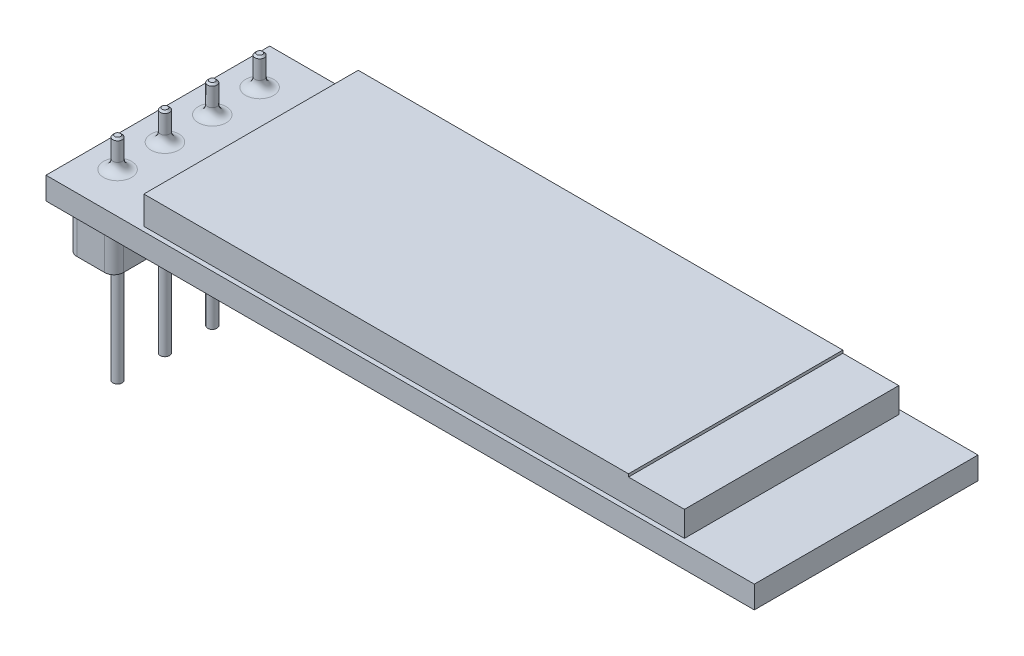
from build123d import *

# Parameters (mm, degrees)
SKETCH1_W                  = 38
SKETCH1_H                  = 12
BOSS_EXTRUDE1_DEPTH        = 1.2
SKETCH2_W                  = 29
SKETCH2_H                  = 11.5
BOSS_EXTRUDE2_DEPTH        = 1.5
BOSS_EXTRUDE3_START        = -9.8
SKETCH3_R                  = 0.25
BOSS_EXTRUDE3_DEPTH        = 11.4
CHAMFER1_SIZE              = 0.1
FILLET1_R                  = 0.5
LPATTERN1_COUNT            = 4
LPATTERN1_PITCH            = 2.54
CHAMFER1_OF_LPATTERN1_SIZE = 0.1
FILLET1_OF_LPATTERN1_R     = 0.5
SKETCH4_W                  = 2.5
SKETCH4_H                  = 10.5
BOSS_EXTRUDE4_DEPTH        = 2.5
FILLET2_R                  = 0.5
SKETCH5_W                  = 3
SKETCH5_H                  = 11.5
CUT_EXTRUDE1_DEPTH         = 0.15


with BuildPart() as part:
    # Sketch1 → Boss-Extrude1 (new body)
    with BuildSketch(Plane(origin=(0, 0, 0), x_dir=(1, 0, 0), z_dir=(0, 1, 0))):
        Rectangle(SKETCH1_W, SKETCH1_H)
    extrude(amount=BOSS_EXTRUDE1_DEPTH)

    # Sketch2 → Boss-Extrude2 (add)
    with BuildSketch(Plane(origin=(0, 1.2, 0), x_dir=(1, 0, 0), z_dir=(0, 1, 0))):
        with Locations((0.5, 0)):
            Rectangle(SKETCH2_W, SKETCH2_H)
    extrude(amount=BOSS_EXTRUDE2_DEPTH)

    # Sketch3 → Boss-Extrude3 (add)
    with BuildSketch(Plane(origin=(0, 1.2, 0), x_dir=(1, 0, 0), z_dir=(0, 1, 0)).offset(BOSS_EXTRUDE3_START)):
        with Locations((-17.35, -3.81)):
            Circle(SKETCH3_R)
    boss_extrude3 = extrude(amount=BOSS_EXTRUDE3_DEPTH)

    # Chamfer1
    chamfer1_edges = [part.edges().sort_by_distance(p)[0] for p in [
        (-17.6, 2.8, 3.81),
    ]]
    chamfer(chamfer1_edges, length=CHAMFER1_SIZE)

    # Fillet1
    fillet1_edges = [part.edges().sort_by_distance(p)[0] for p in [
        (-17.6, 1.2, 3.81),
    ]]
    fillet(fillet1_edges, radius=FILLET1_R)

    # LPattern1: Boss-Extrude3 ×4
    with Locations(*[(0, 0, -i * LPATTERN1_PITCH) for i in range(1, LPATTERN1_COUNT)]):
        add(boss_extrude3)

    # Chamfer1 of LPattern1
    chamfer1_of_lpattern1_edges = [part.edges().sort_by_distance(p)[0] for p in [
        (-17.6, 2.8, 1.27),
        (-17.6, 2.8, -1.27),
        (-17.6, 2.8, -3.81),
    ]]
    chamfer(chamfer1_of_lpattern1_edges, length=CHAMFER1_OF_LPATTERN1_SIZE)

    # Fillet1 of LPattern1
    fillet1_of_lpattern1_edges = [part.edges().sort_by_distance(p)[0] for p in [
        (-17.6, 1.2, 1.27),
        (-17.6, 1.2, -1.27),
        (-17.6, 1.2, -3.81),
    ]]
    fillet(fillet1_of_lpattern1_edges, radius=FILLET1_OF_LPATTERN1_R)

    # Sketch4 → Boss-Extrude4 (add)
    with BuildSketch(Plane.XZ):
        with Locations((-17.35, 0)):
            Rectangle(SKETCH4_W, SKETCH4_H)
    extrude(amount=BOSS_EXTRUDE4_DEPTH)

    # Fillet2
    fillet2_edges = [part.edges().sort_by_distance(p)[0] for p in [
        (-16.1, -1.25, -5.25),
        (-16.1, -1.25, 5.25),
        (-18.6, -1.25, 5.25),
        (-18.6, -1.25, -5.25),
    ]]
    fillet(fillet2_edges, radius=FILLET2_R)

    # Sketch5 → Cut-Extrude1 (cut)
    with BuildSketch(Plane(origin=(0, 2.7, 0), x_dir=(1, 0, 0), z_dir=(0, 1, 0))):
        with Locations((13.5, 0)):
            Rectangle(SKETCH5_W, SKETCH5_H)
    extrude(amount=-CUT_EXTRUDE1_DEPTH, mode=Mode.SUBTRACT)


solid = part.part
